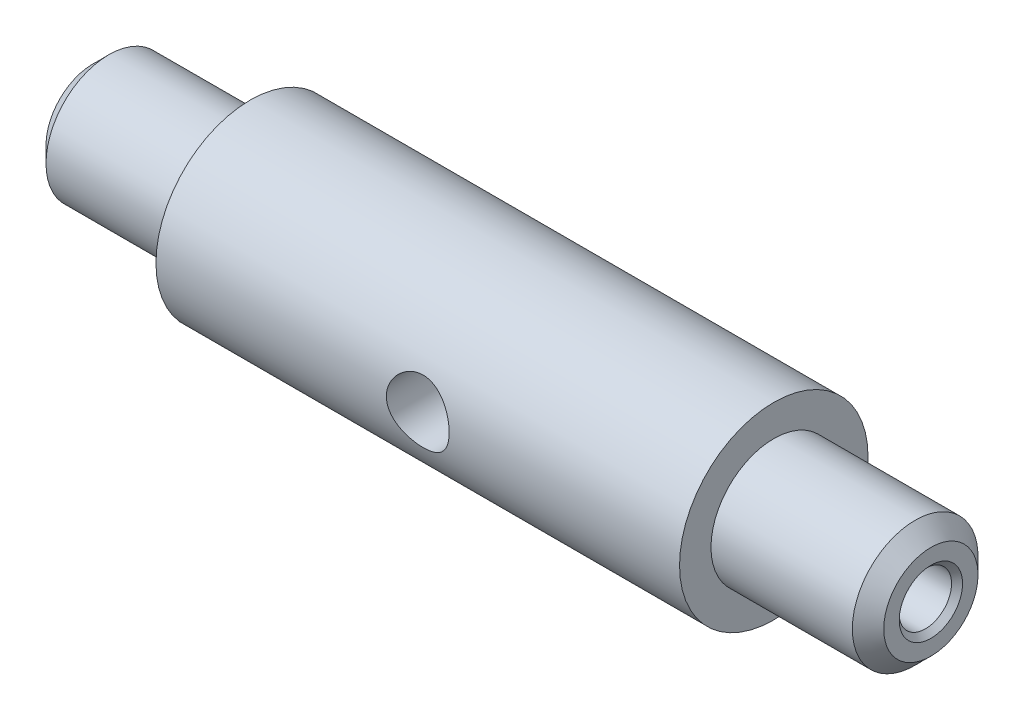
from build123d import *

# Parameters (mm, degrees)
M6X1_0_TAPPED_HOLE1_D           = 5
M6X1_0_TAPPED_HOLE1_DEPTH       = 45
M6X1_0_TAPPED_HOLE1_CSINK_D     = 6.05
M6X1_0_TAPPED_HOLE1_CSINK_ANGLE = 90
M6X1_0_TAPPED_HOLE1_TIP         = 1.502151548
SKETCH5_R                       = 3
CUT_EXTRUDE1_DEPTH              = 10
CUT_EXTRUDE1_DEPTH_BACK         = 10
CHAMFER1_SIZE                   = 1.5


with BuildPart() as part:
    # Sketch1 → Revolve4 (revolve)
    with BuildSketch(Plane(origin=(0, 0, 0), x_dir=(1, 0, 0), z_dir=(0, 1, 0))):
        Polygon((0, 6), (15, 6), (15, 9), (65, 9), (65, 6), (80, 6), (80, 0), (0, 0), align=None)
    revolve(axis=Axis((0, 0, 0), (1, 0, 0)))

    # M6x1.0 Tapped Hole1
    with Locations(Plane(origin=(80, 0, 0), x_dir=(0, 0, -1), z_dir=(1, 0, 0))):
        with Locations((0, 0)):
            CounterSinkHole(M6X1_0_TAPPED_HOLE1_D / 2, M6X1_0_TAPPED_HOLE1_CSINK_D / 2, depth=M6X1_0_TAPPED_HOLE1_DEPTH, counter_sink_angle=M6X1_0_TAPPED_HOLE1_CSINK_ANGLE)
            with Locations((0, 0, -(M6X1_0_TAPPED_HOLE1_DEPTH + M6X1_0_TAPPED_HOLE1_TIP / 2))):  # 118° drill point
                Cone(0, M6X1_0_TAPPED_HOLE1_D / 2, M6X1_0_TAPPED_HOLE1_TIP, mode=Mode.SUBTRACT)

    # Sketch5 → Cut-Extrude1 (cut, two sides)
    with BuildSketch(Plane.XY) as cut_extrude1_sk:
        with Locations((40, 0)):
            Circle(SKETCH5_R)
    extrude(amount=CUT_EXTRUDE1_DEPTH, mode=Mode.SUBTRACT)
    extrude(cut_extrude1_sk.sketch, amount=-CUT_EXTRUDE1_DEPTH_BACK, mode=Mode.SUBTRACT)

    # Chamfer1
    chamfer1_edges = [part.edges().sort_by_distance(p)[0] for p in [
        (0, 0, 6),
        (80, 0, 6),
    ]]
    chamfer(chamfer1_edges, length=CHAMFER1_SIZE)


solid = part.part
